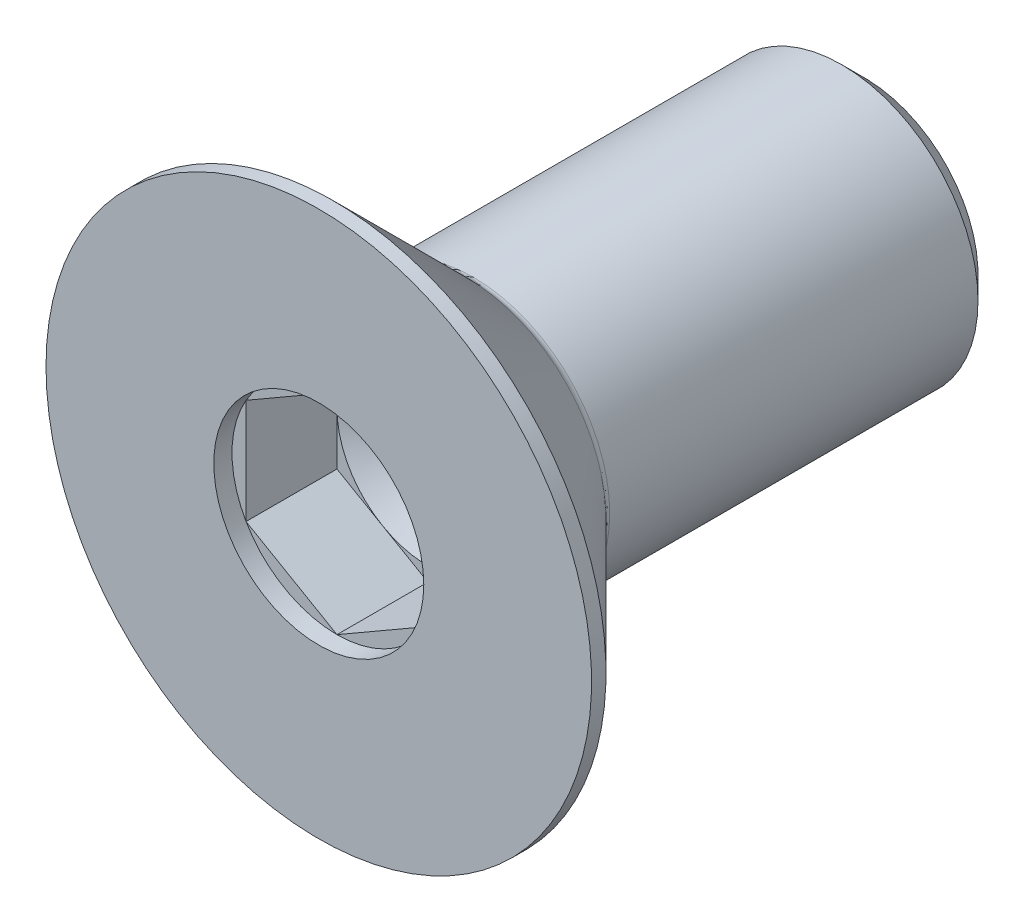
from build123d import *

# Parameters (mm, degrees)
CUT_EXTRUDE1_DEPTH = 1.2
SKETCH5_R          = 1.154700538
CUT_EXTRUDE2_DEPTH = 0.2


with BuildPart() as part:
    # Sketch2 → Revolve1 (revolve)
    with BuildSketch(Plane(origin=(0, 0, 0), x_dir=(0, 0, -1), z_dir=(1, 0, 0))):
        with BuildLine():
            Line((0, 0), (0, 3))
            Line((0, 3), (0.158578644, 3))
            Line((0.158578644, 3), (1.629289322, 1.529289322))
            ThreePointArc((1.629289322, 1.529289322), (1.661731657, 1.507612047), (1.7, 1.5))
            Line((1.7, 1.5), (5.75, 1.5))
            Line((5.75, 1.5), (6, 1.25))
            Line((6, 1.25), (6, 0))
            Line((6, 0), (0, 0))
        make_face()
    revolve(axis=Axis((0, 0, 0), (0, 0, 1)))

    # Sketch3 → Cut-Extrude1 (cut)
    with BuildSketch(Plane.XY):
        Polygon((0, 1.154700538), (-1, 0.577350269), (-1, -0.577350269), (0, -1.154700538), (1, -0.577350269), (1, 0.577350269), align=None)
    extrude(amount=-CUT_EXTRUDE1_DEPTH, mode=Mode.SUBTRACT)

    # Sketch4 → Cut-Revolve1 (revolve, cut)
    with BuildSketch(Plane(origin=(0, 0, 0), x_dir=(0, 0, -1), z_dir=(1, 0, 0))):
        Polygon((1.2, 0), (1.2, 1), (1.777350269, 0), align=None)
    revolve(axis=Axis((0, 0, 0), (0, 0, -1)), mode=Mode.SUBTRACT)

    # Sketch5 → Cut-Extrude2 (cut)
    with BuildSketch(Plane.XY):
        Circle(SKETCH5_R)
    extrude(amount=-CUT_EXTRUDE2_DEPTH, mode=Mode.SUBTRACT)


solid = part.part
